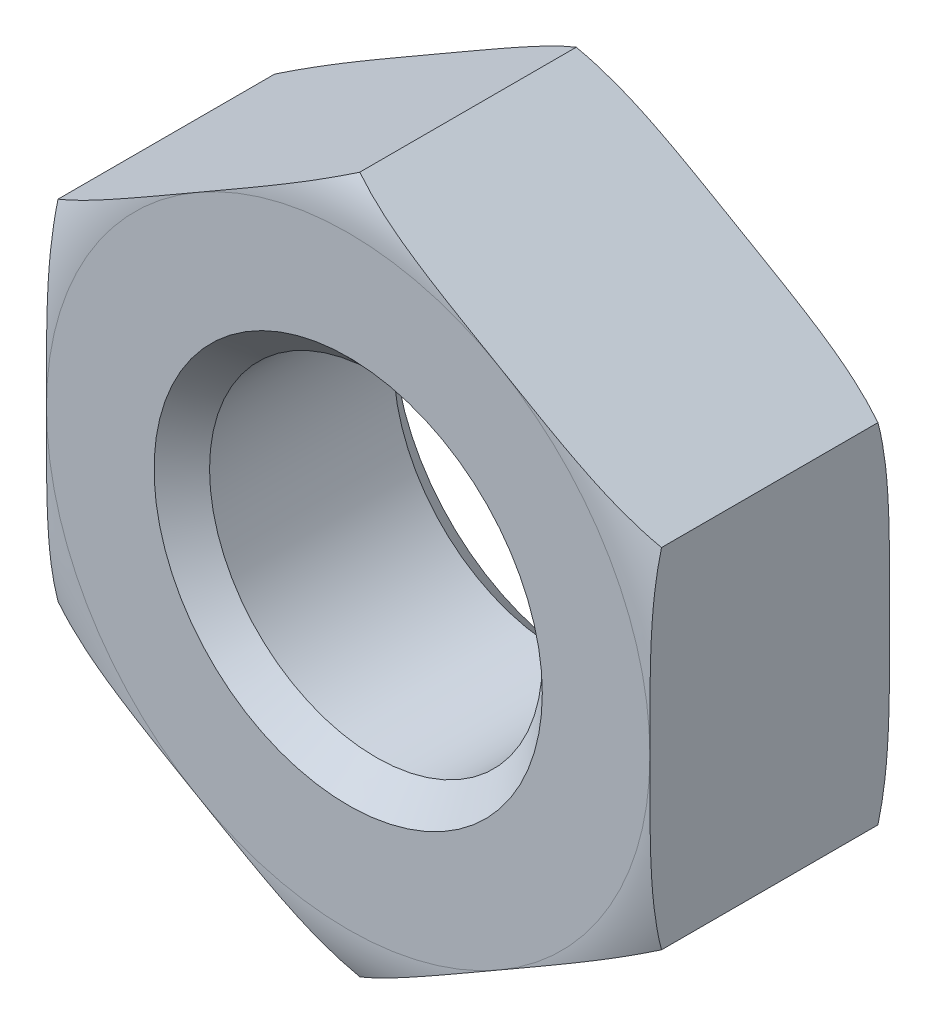
from build123d import *

# Parameters (mm, degrees)
SKETCH1_R           = 1.5
BOSS_EXTRUDE1_DEPTH = 2.16
CHAMFER1_SIZE       = 0.25


with BuildPart() as part:
    # Sketch1 → Boss-Extrude1 (new body)
    with BuildSketch(Plane.XY):
        Polygon((2.72, 1.570392732), (0, 3.140785464), (-2.72, 1.570392732), (-2.72, -1.570392732), (0, -3.140785464), (2.72, -1.570392732), align=None)
        Circle(SKETCH1_R, mode=Mode.SUBTRACT)
    extrude(amount=BOSS_EXTRUDE1_DEPTH)

    # Chamfer1
    chamfer1_edges = [part.edges().sort_by_distance(p)[0] for p in [
        (-1.5, 0, 0),
        (-1.5, 0, 2.16),
    ]]
    chamfer(chamfer1_edges, length=CHAMFER1_SIZE)

    # Sketch2 → Cut-Revolve1 (revolve, cut)
    with BuildSketch(Plane(origin=(0, 0, 0), x_dir=(1, 0, 0), z_dir=(0, 1, 0))):
        with BuildLine():
            Line((-3.580128719, -0.636846199), (-4.500819954, -0.636846199))
            Line((-4.500819954, -0.636846199), (-4.500819954, 0.361239255))
            Line((-4.500819954, 0.361239255), (-2.72, 0.361239255))
            Line((-2.72, 0.361239255), (-2.72, 0))
            ThreePointArc((-2.72, 0), (-3.255115524, -0.176540297), (-3.580128719, -0.636846199))
        make_face()
        with BuildLine():
            Line((-2.72, -2.521239255), (-2.72, -2.16))
            ThreePointArc((-2.72, -2.16), (-3.255115524, -1.983459703), (-3.580128719, -1.523153801))
            Line((-3.580128719, -1.523153801), (-4.500819954, -1.523153801))
            Line((-4.500819954, -1.523153801), (-4.500819954, -2.521239255))
            Line((-4.500819954, -2.521239255), (-2.72, -2.521239255))
        make_face()
    revolve(axis=Axis((0, 0, 1.08), (0, 0, -1)), mode=Mode.SUBTRACT)


solid = part.part
